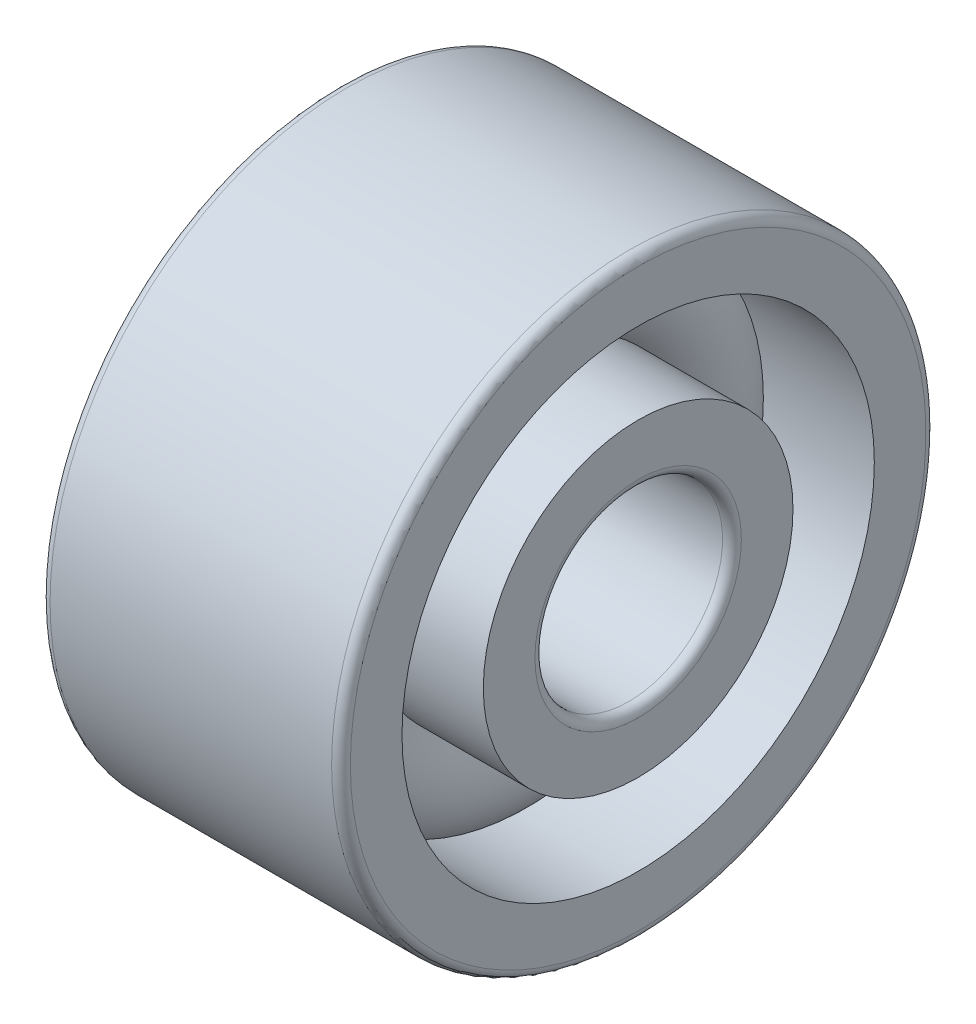
from build123d import *


with BuildPart() as part:
    # Sketch1 → Revolve1 (revolve)
    with BuildSketch(Plane(origin=(0, 0, 0.115859753), x_dir=(-1, 0, 0), z_dir=(0, 0, -1))):
        with BuildLine():
            Line((-1.607580359, 6.629201388), (-6.336321445, 6.629201388))
            Line((-6.336321445, 6.629201388), (-6.336321445, 4.429201388))
            ThreePointArc((-6.336321445, 4.429201388), (-6.219164158, 4.146358676), (-5.936321445, 4.029201388))
            Line((-5.936321445, 4.029201388), (6.063678555, 4.029201388))
            ThreePointArc((6.063678555, 4.029201388), (6.346521267, 4.146358676), (6.463678555, 4.429201388))
            Line((6.463678555, 4.429201388), (6.463678555, 6.629201388))
            Line((6.463678555, 6.629201388), (2.268270802, 6.629201388))
            ThreePointArc((2.268270802, 6.629201388), (2.930345222, 8.362534721), (2.268270802, 10.095868055))
            Line((2.268270802, 10.095868055), (6.463678555, 10.095868055))
            Line((6.463678555, 10.095868055), (6.463678555, 12.295868055))
            ThreePointArc((6.463678555, 12.295868055), (6.346521267, 12.578710767), (6.063678555, 12.695868055))
            Line((6.063678555, 12.695868055), (-5.936321445, 12.695868055))
            ThreePointArc((-5.936321445, 12.695868055), (-6.219164158, 12.578710767), (-6.336321445, 12.295868055))
            Line((-6.336321445, 12.295868055), (-6.336321445, 10.095868055))
            Line((-6.336321445, 10.095868055), (-1.607580359, 10.095868055))
            ThreePointArc((-1.607580359, 10.095868055), (-2.269654778, 8.362534721), (-1.607580359, 6.629201388))
        make_face()
    revolve(axis=Axis((6.336321445, 0.029201388, 0.115859753), (-1, 0, 0)))


solid = part.part
